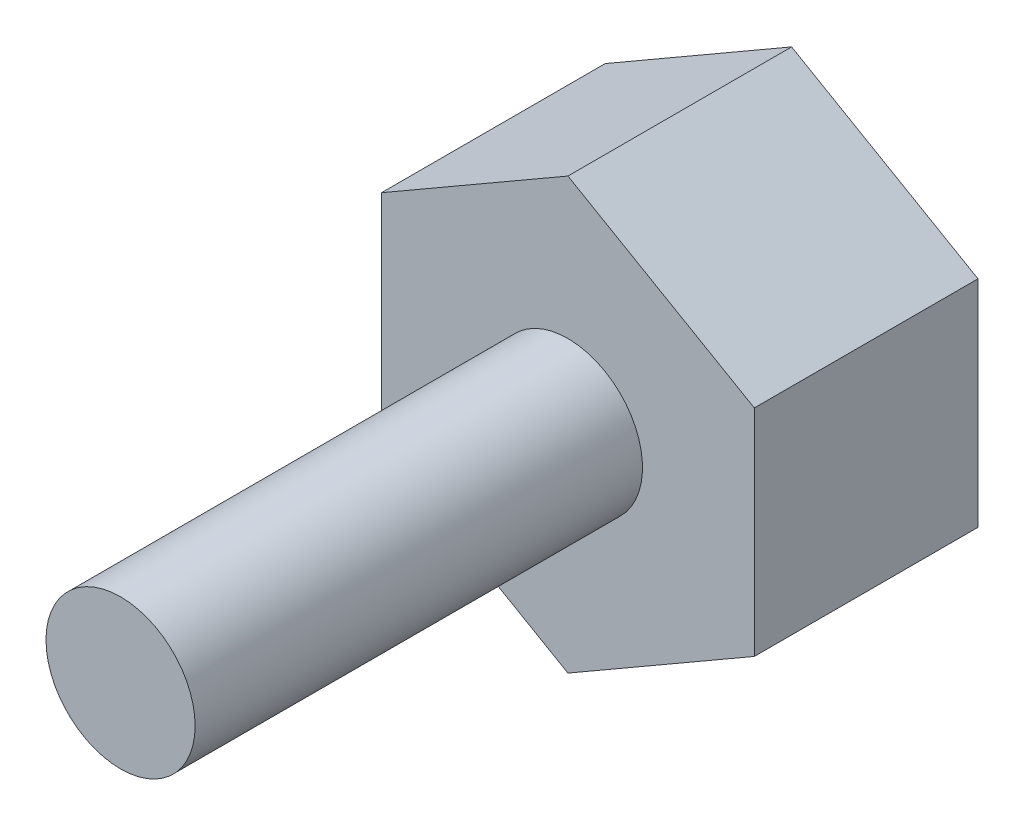
from build123d import *

# Parameters (mm, degrees)
SKETCH1_R           = 1
BOSS_EXTRUDE1_DEPTH = 6
BOSS_EXTRUDE2_DEPTH = 3


with BuildPart() as part:
    # Sketch1 → Boss-Extrude1 (new body)
    with BuildSketch(Plane.XY):
        with Locations((-63.49476159, 14.978708134)):
            Circle(SKETCH1_R)
    extrude(amount=BOSS_EXTRUDE1_DEPTH)

    # Sketch2 → Boss-Extrude2 (add)
    with BuildSketch(Plane(origin=(0, 0, 0), x_dir=(-1, 0, 0), z_dir=(0, 0, -1))):
        Polygon((63.49476159, 12.091956788), (65.99476159, 13.535332461), (65.99476159, 16.422083807), (63.49476159, 17.86545948), (60.99476159, 16.422083807), (60.99476159, 13.535332461), align=None)
    extrude(amount=BOSS_EXTRUDE2_DEPTH)


solid = part.part
